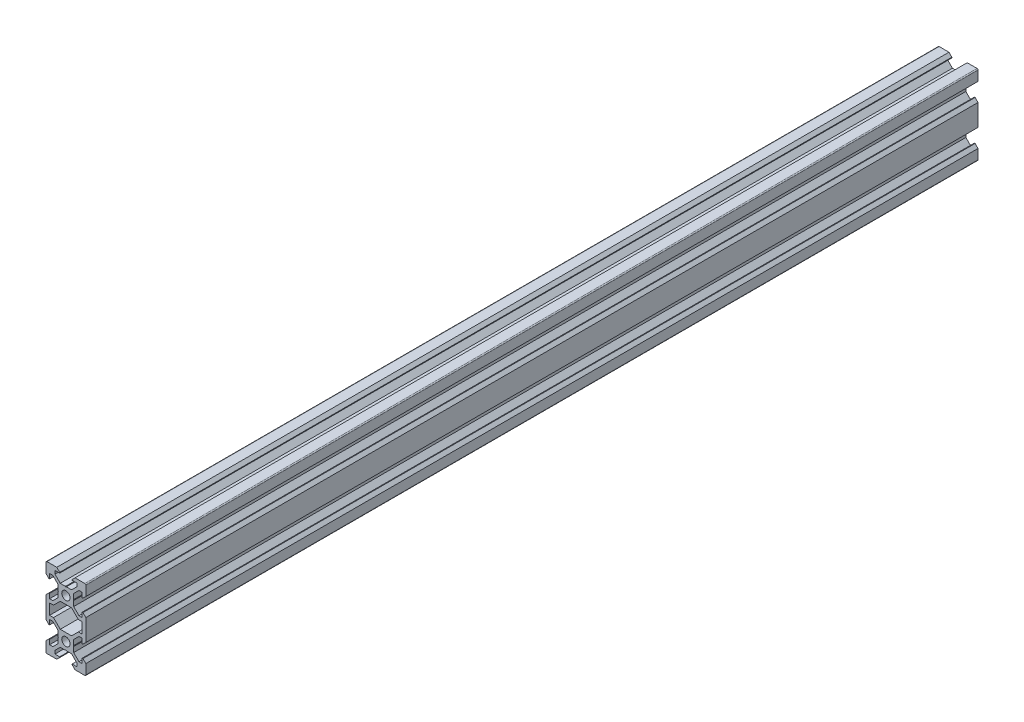
from build123d import *

# Parameters (mm, degrees)
SKETCH1_R           = 2.1
BOSS_EXTRUDE1_DEPTH = 448


with BuildPart() as part:
    # Sketch1 → Boss-Extrude1 (new body)
    with BuildSketch(Plane.XY):
        with BuildLine():
            Line((4.58, -20), (9.5, -20))
            ThreePointArc((9.5, -20), (9.853553391, -19.853553391), (10, -19.5))
            Line((10, -19.5), (10, -14.58))
            Line((10, -14.58), (8.545, -13.125))
            Line((8.545, -13.125), (8.2, -13.125))
            Line((8.2, -13.125), (8.2, -15.5))
            Line((8.2, -15.5), (6.560660172, -15.5))
            Line((6.560660172, -15.5), (3.9, -12.839339828))
            Line((3.9, -12.839339828), (3.9, -10.21))
            Line((3.9, -10.21), (3.69, -10))
            Line((3.69, -10), (3.9, -9.79))
            Line((3.9, -9.79), (3.9, -7.160660172))
            Line((3.9, -7.160660172), (6.560660172, -4.5))
            Line((6.560660172, -4.5), (8.2, -4.5))
            Line((8.2, -4.5), (8.2, -6.875))
            Line((8.2, -6.875), (8.545, -6.875))
            Line((8.545, -6.875), (10, -5.42))
            Line((10, -5.42), (10, 5.42))
            Line((10, 5.42), (8.545, 6.875))
            Line((8.545, 6.875), (8.2, 6.875))
            Line((8.2, 6.875), (8.2, 4.5))
            Line((8.2, 4.5), (6.560660172, 4.5))
            Line((6.560660172, 4.5), (3.9, 7.160660172))
            Line((3.9, 7.160660172), (3.9, 9.79))
            Line((3.9, 9.79), (3.69, 10))
            Line((3.69, 10), (3.9, 10.21))
            Line((3.9, 10.21), (3.9, 12.839339828))
            Line((3.9, 12.839339828), (6.560660172, 15.5))
            Line((6.560660172, 15.5), (8.2, 15.5))
            Line((8.2, 15.5), (8.2, 13.125))
            Line((8.2, 13.125), (8.545, 13.125))
            Line((8.545, 13.125), (10, 14.58))
            Line((10, 14.58), (10, 19.5))
            ThreePointArc((10, 19.5), (9.853553391, 19.853553391), (9.5, 20))
            Line((9.5, 20), (4.58, 20))
            Line((4.58, 20), (3.125, 18.545))
            Line((3.125, 18.545), (3.125, 18.2))
            Line((3.125, 18.2), (5.5, 18.2))
            Line((5.5, 18.2), (5.5, 16.560660172))
            Line((5.5, 16.560660172), (2.839339828, 13.9))
            Line((2.839339828, 13.9), (0.21, 13.9))
            Line((0.21, 13.9), (0, 13.69))
            Line((0, 13.69), (-0.21, 13.9))
            Line((-0.21, 13.9), (-2.839339828, 13.9))
            Line((-2.839339828, 13.9), (-5.5, 16.560660172))
            Line((-5.5, 16.560660172), (-5.5, 18.2))
            Line((-5.5, 18.2), (-3.125, 18.2))
            Line((-3.125, 18.2), (-3.125, 18.545))
            Line((-3.125, 18.545), (-4.58, 20))
            Line((-4.58, 20), (-9.5, 20))
            ThreePointArc((-9.5, 20), (-9.853553391, 19.853553391), (-10, 19.5))
            Line((-10, 19.5), (-10, 14.58))
            Line((-10, 14.58), (-8.545, 13.125))
            Line((-8.545, 13.125), (-8.2, 13.125))
            Line((-8.2, 13.125), (-8.2, 15.5))
            Line((-8.2, 15.5), (-6.560660172, 15.5))
            Line((-6.560660172, 15.5), (-3.9, 12.839339828))
            Line((-3.9, 12.839339828), (-3.9, 10.21))
            Line((-3.9, 10.21), (-3.69, 10))
            Line((-3.69, 10), (-3.9, 9.79))
            Line((-3.9, 9.79), (-3.9, 7.160660172))
            Line((-3.9, 7.160660172), (-6.560660172, 4.5))
            Line((-6.560660172, 4.5), (-8.2, 4.5))
            Line((-8.2, 4.5), (-8.2, 6.875))
            Line((-8.2, 6.875), (-8.545, 6.875))
            Line((-8.545, 6.875), (-10, 5.42))
            Line((-10, 5.42), (-10, -5.42))
            Line((-10, -5.42), (-8.545, -6.875))
            Line((-8.545, -6.875), (-8.2, -6.875))
            Line((-8.2, -6.875), (-8.2, -4.5))
            Line((-8.2, -4.5), (-6.560660172, -4.5))
            Line((-6.560660172, -4.5), (-3.9, -7.160660172))
            Line((-3.9, -7.160660172), (-3.9, -9.79))
            Line((-3.9, -9.79), (-3.69, -10))
            Line((-3.69, -10), (-3.9, -10.21))
            Line((-3.9, -10.21), (-3.9, -12.839339828))
            Line((-3.9, -12.839339828), (-6.560660172, -15.5))
            Line((-6.560660172, -15.5), (-8.2, -15.5))
            Line((-8.2, -15.5), (-8.2, -13.125))
            Line((-8.2, -13.125), (-8.545, -13.125))
            Line((-8.545, -13.125), (-10, -14.58))
            Line((-10, -14.58), (-10, -19.5))
            ThreePointArc((-10, -19.5), (-9.853553391, -19.853553391), (-9.5, -20))
            Line((-9.5, -20), (-4.58, -20))
            Line((-4.58, -20), (-3.125, -18.545))
            Line((-3.125, -18.545), (-3.125, -18.2))
            Line((-3.125, -18.2), (-5.5, -18.2))
            Line((-5.5, -18.2), (-5.5, -16.560660172))
            Line((-5.5, -16.560660172), (-2.839339828, -13.9))
            Line((-2.839339828, -13.9), (-0.21, -13.9))
            Line((-0.21, -13.9), (0, -13.69))
            Line((0, -13.69), (0.21, -13.9))
            Line((0.21, -13.9), (2.839339828, -13.9))
            Line((2.839339828, -13.9), (5.5, -16.560660172))
            Line((5.5, -16.560660172), (5.5, -18.2))
            Line((5.5, -18.2), (3.125, -18.2))
            Line((3.125, -18.2), (3.125, -18.545))
            Line((3.125, -18.545), (4.58, -20))
        make_face()
        with Locations((0, -10)):
            Circle(SKETCH1_R, mode=Mode.SUBTRACT)
        Polygon((-6.239339828, -2.7), (-8.2, -2.7), (-8.2, 2.7), (-6.239339828, 2.7), (-2.839339828, 6.1), (2.839339828, 6.1), (6.239339828, 2.7), (8.2, 2.7), (8.2, -2.7), (6.239339828, -2.7), (2.839339828, -6.1), (-2.839339828, -6.1), align=None, mode=Mode.SUBTRACT)
        with Locations((0, 10)):
            Circle(SKETCH1_R, mode=Mode.SUBTRACT)
    extrude(amount=BOSS_EXTRUDE1_DEPTH)


solid = part.part
